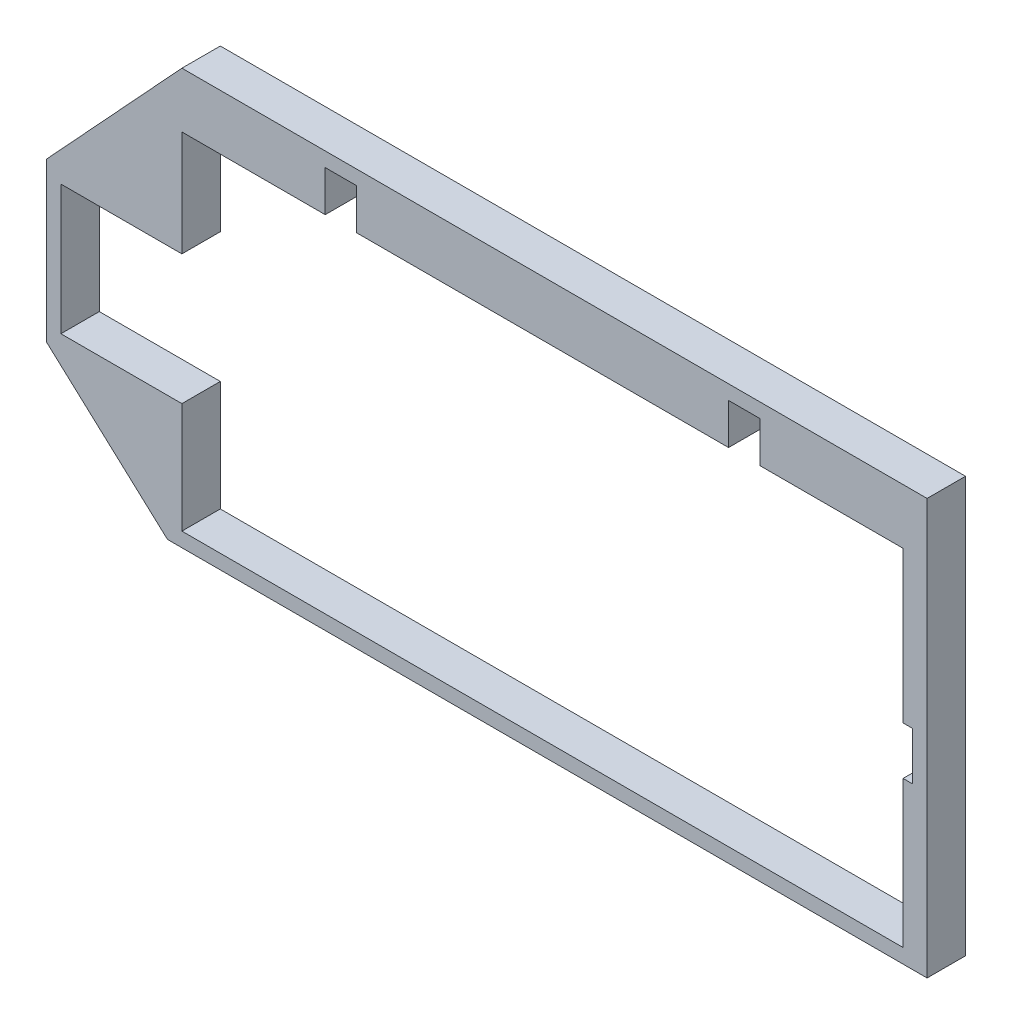
from build123d import *

# Parameters (mm, degrees)
BOSS_EXTRUDE1_DEPTH = 8


with BuildPart() as part:
    # Sketch1 → Boss-Extrude1 (new body)
    with BuildSketch(Plane.XY):
        Polygon((-178.4, 53), (-150.2, 83.5), (5, 83.5), (5, -3), (-153.2, -3), (-178.4, 20), align=None)
        Polygon((-150.2, 72), (-120.35, 72), (-120.35, 80.5), (-113.85, 80.5), (-113.85, 72), (-36.35, 72), (-36.35, 80.5), (-29.85, 80.5), (-29.85, 72), (0, 72), (0, 40.5), (2, 40.5), (2, 30.5), (0, 30.5), (0, 0), (-150.2, 0), (-150.2, 23), (-175.4, 23), (-175.4, 50), (-150.2, 50), align=None, mode=Mode.SUBTRACT)
    extrude(amount=BOSS_EXTRUDE1_DEPTH)


solid = part.part
